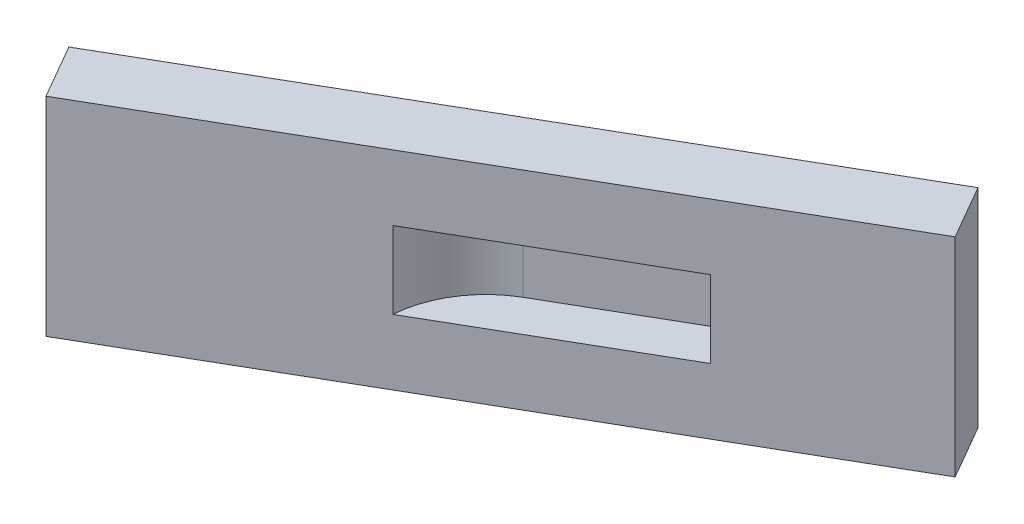
from build123d import *

# Parameters (mm, degrees)
EXTRUDE_1_DEPTH      = 5
EXTRUDE_1_DEPTH_BACK = 5
CUT_EXTRUDE_1_DEPTH  = 1.85


with BuildPart() as part:
    # 草圖2 → 填料-伸長1 (new, two sides: drawn at the far end of the back side and taken through both)
    with BuildSketch(Plane(origin=(0, 0, 0), x_dir=(1, 0, 0), z_dir=(0, 1, 0)).offset(-EXTRUDE_1_DEPTH_BACK)):
        Polygon((1.795278459, 12.659996299), (0.295278459, 15.25807251), (-27.417534462, -0.74192749), (-25.917534462, -3.340003701), align=None)
    extrude(amount=EXTRUDE_1_DEPTH + EXTRUDE_1_DEPTH_BACK)

    # 草圖2<7> → 除料-伸長1 (cut, symmetric)
    with BuildSketch(Plane(origin=(0, 0, 0), x_dir=(1, 0, 0), z_dir=(0, 1, 0))):
        with BuildLine():
            Line((-15.35631853, -0.706584455), (-15.35631853, 2.4))
            ThreePointArc((-15.35631853, 2.4), (-14.706541739, 4.825), (-12.93131853, 6.600223208))
            Line((-12.93131853, 6.600223208), (-5.65631853, 10.800446417))
            Line((-5.65631853, 10.800446417), (-5.65631853, 4.893713156))
            Line((-5.65631853, 4.893713156), (-15.35631853, -0.706584455))
        make_face()
    extrude(amount=CUT_EXTRUDE_1_DEPTH, both=True, mode=Mode.SUBTRACT)


solid = part.part
